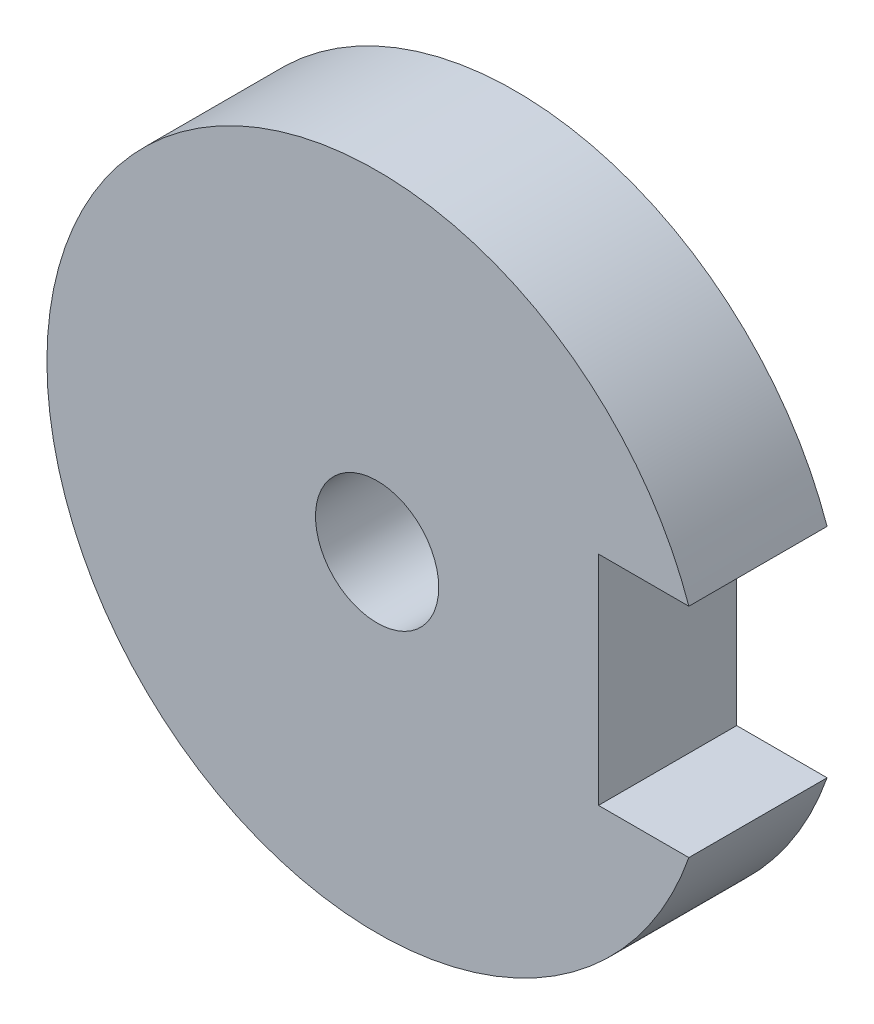
from build123d import *

# Parameters (mm, degrees)
SKETCH1_R           = 7.585
SKETCH1_R_2         = 1.415
BOSS_EXTRUDE1_DEPTH = 3.175
SKETCH2_W           = 2.5
SKETCH2_H           = 5
CUT_EXTRUDE1_DEPTH  = 3.175


with BuildPart() as part:
    # Sketch1 → Boss-Extrude1 (new body)
    with BuildSketch(Plane.XY):
        Circle(SKETCH1_R)
        Circle(SKETCH1_R_2, mode=Mode.SUBTRACT)
    extrude(amount=BOSS_EXTRUDE1_DEPTH)

    # Sketch2 → Cut-Extrude1 (cut)
    with BuildSketch(Plane.XY.offset(3.175)):
        with Locations((6.335, 0)):
            Rectangle(SKETCH2_W, SKETCH2_H)
    extrude(amount=-CUT_EXTRUDE1_DEPTH, mode=Mode.SUBTRACT)


solid = part.part
